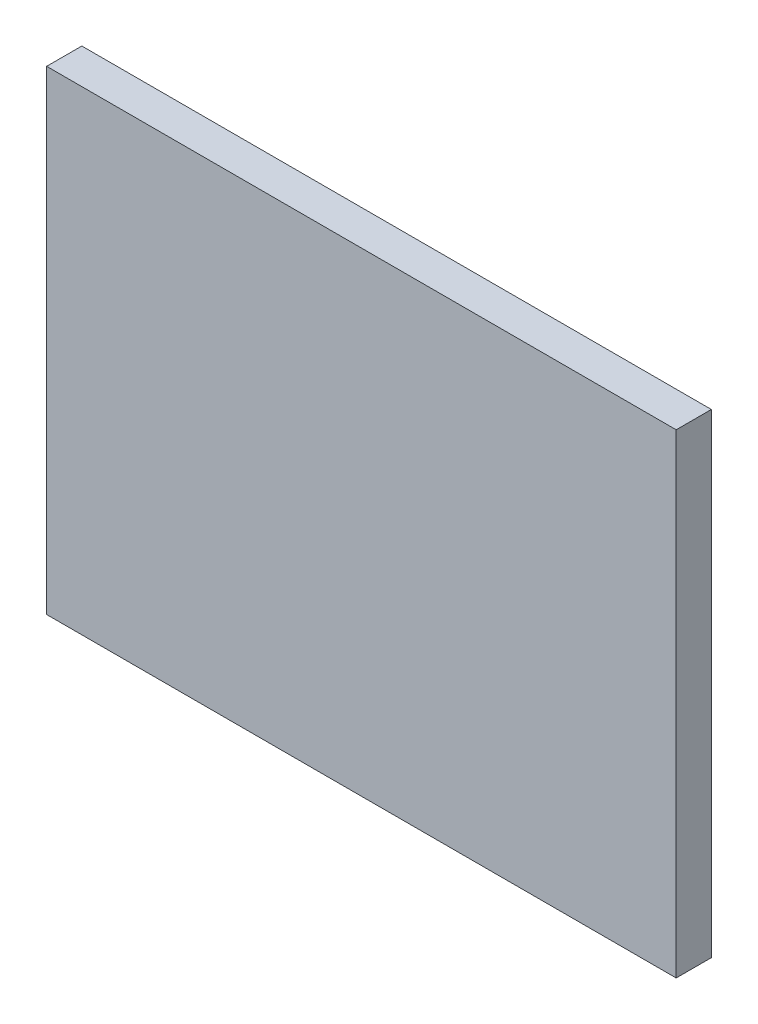
from build123d import *

# Parameters (mm, degrees)
SKETCH1_W           = 35.8
SKETCH1_H           = 27
BOSS_EXTRUDE1_DEPTH = 2


with BuildPart() as part:
    # Sketch1 → Boss-Extrude1 (new body)
    with BuildSketch(Plane.XY):
        Rectangle(SKETCH1_W, SKETCH1_H)
    extrude(amount=BOSS_EXTRUDE1_DEPTH)


solid = part.part
